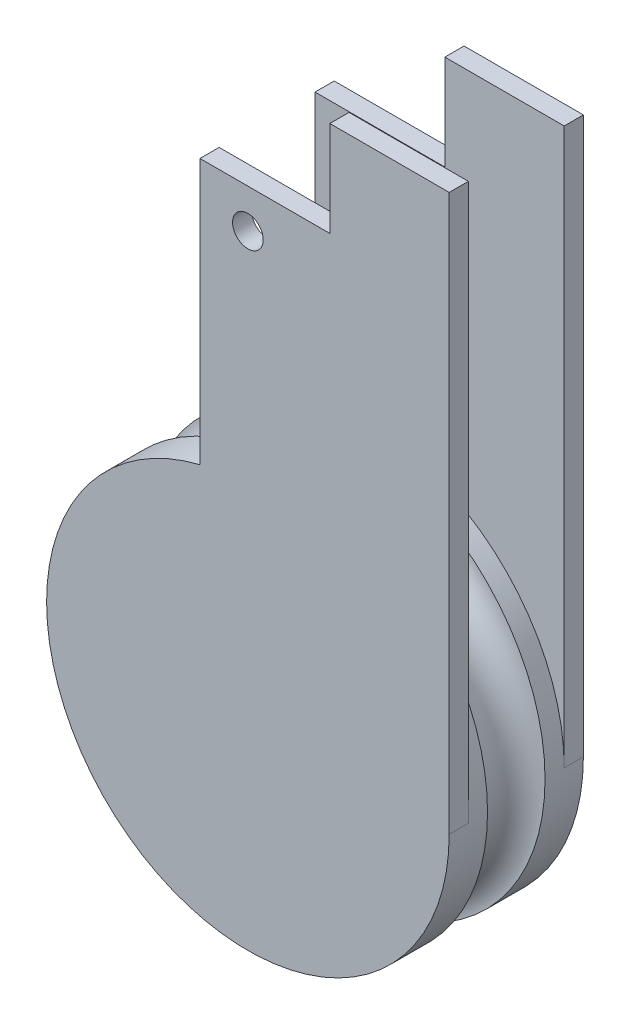
from build123d import *

# Parameters (mm, degrees)
SKETCH1_R           = 8
BOSS_EXTRUDE1_DEPTH = 5
BOSS_EXTRUDE2_START = 5
SKETCH1_3_R         = 105
BOSS_EXTRUDE2_DEPTH = 50
BOSS_EXTRUDE3_START = 55
SKETCH1_4_R         = 8
SKETCH1_4_R_2       = 105
BOSS_EXTRUDE3_DEPTH = 10
SKETCH2_R           = 15


with BuildPart() as part:
    # Sketch1 → Boss-Extrude1 (new body, symmetric)
    with BuildSketch(Plane.XY):
        with BuildLine():
            Line((-25, 240.330386365), (-25, 101.980390272))
            ThreePointArc((-25, 101.980390272), (-64.807406984, -82.613558209), (105, 0))
            Line((105, 0), (105, 290))
            Line((105, 290), (42.740477075, 290))
            Line((42.740477075, 290), (42.740477075, 240.330386365))
            Line((42.740477075, 240.330386365), (-25, 240.330386365))
        make_face()
        with Locations((0, 220)):
            Circle(SKETCH1_R, mode=Mode.SUBTRACT)
    extrude(amount=BOSS_EXTRUDE1_DEPTH, both=True)

    # Sketch1_3 → Boss-Extrude2 (add)
    with BuildSketch(Plane.XY.offset(BOSS_EXTRUDE2_START)):
        Circle(SKETCH1_3_R)
    extrude(amount=BOSS_EXTRUDE2_DEPTH)

    # Sketch1_4 → Boss-Extrude3 (add)
    with BuildSketch(Plane.XY.offset(BOSS_EXTRUDE3_START)):
        with BuildLine():
            ThreePointArc((-25, 101.980390272), (64.807406984, 82.613558209), (105, 0))
            Line((105, 0), (105, 290))
            Line((105, 290), (42.740477075, 290))
            Line((42.740477075, 290), (42.740477075, 240.330386365))
            Line((42.740477075, 240.330386365), (-25, 240.330386365))
            Line((-25, 240.330386365), (-25, 101.980390272))
        make_face()
        with Locations((0, 220)):
            Circle(SKETCH1_4_R, mode=Mode.SUBTRACT)
        Circle(SKETCH1_4_R_2)
    extrude(amount=BOSS_EXTRUDE3_DEPTH)


with BuildPart() as body_2:
    # Sketch2 → Revolve1 (revolve)
    with BuildSketch(Plane(origin=(0, 0, 0), x_dir=(0, 0, -1), z_dir=(1, 0, 0))):
        with Locations((-30, 105)):
            Circle(SKETCH2_R)
    revolve(axis=Axis((0, 0, 45), (0, 0, -1)))


with BuildPart() as part_1:
    add(part.part)

    # Combine1: cut body 2
    add(body_2.part, mode=Mode.SUBTRACT)


solid = part_1.part
